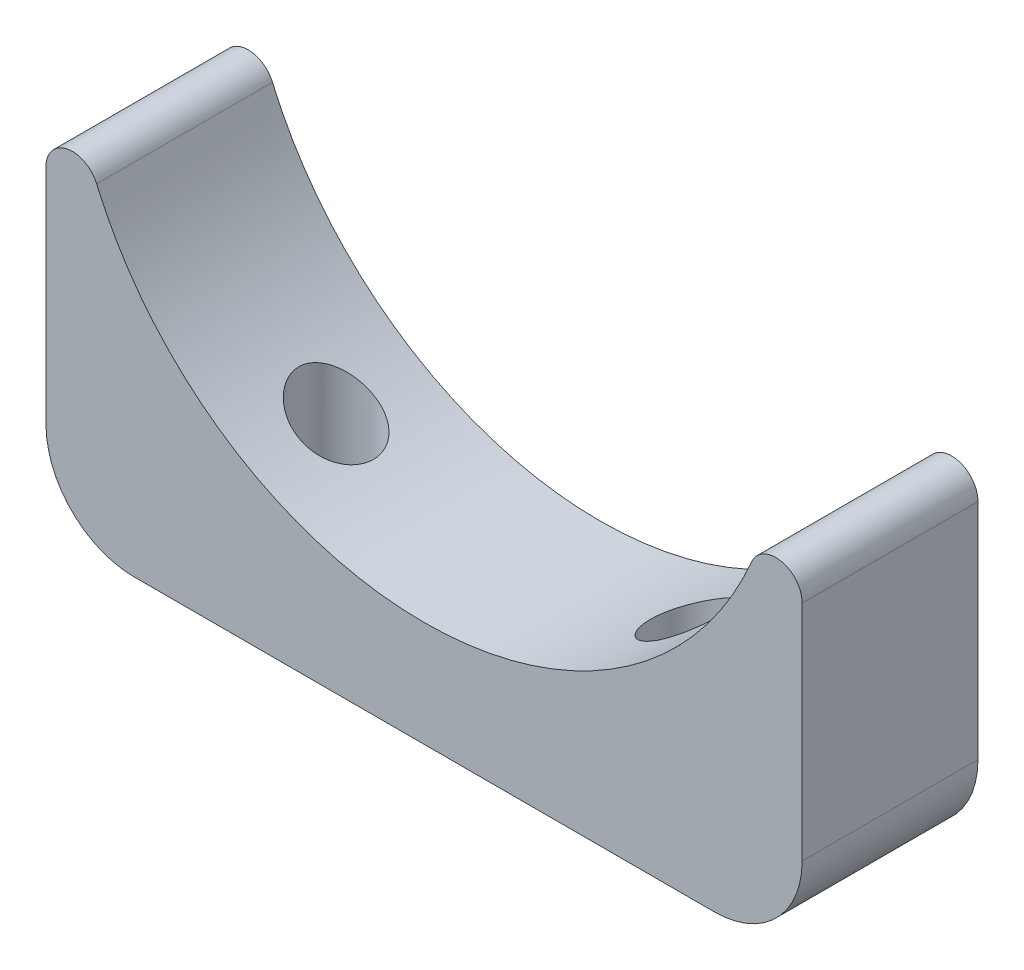
from build123d import *

# Parameters (mm, degrees)
BASE_EXTRUDE_DEPTH = 10
HOLE1_D            = 8.5
HOLE1_DEPTH        = 30
HOLE1_TIP          = 2.553657631


with BuildPart() as part:
    # Sketch1 → Base-Extrude (new body, symmetric)
    with BuildSketch(Plane.XY):
        with BuildLine():
            Line((43, -17.095320997), (43, -42.5))
            ThreePointArc((43, -42.5), (40.071067812, -49.571067812), (33, -52.5))
            Line((33, -52.5), (-33, -52.5))
            ThreePointArc((-33, -52.5), (-40.071067812, -49.571067812), (-43, -42.5))
            Line((-43, -42.5), (-43, -17.095320997))
            ThreePointArc((-43, -17.095320997), (-40.601721668, -14.156285265), (-37.24137931, -15.916333342))
            ThreePointArc((-37.24137931, -15.916333342), (0, -40.5), (37.24137931, -15.916333342))
            ThreePointArc((37.24137931, -15.916333342), (40.601721668, -14.156285265), (43, -17.095320997))
        make_face()
    extrude(amount=BASE_EXTRUDE_DEPTH, both=True)

    # Hole1
    with Locations(Plane.XZ.offset(52.5)):
        with Locations((-20, 0), (20, 0)):
            Hole(HOLE1_D / 2, depth=HOLE1_DEPTH)
            with Locations((0, 0, -(HOLE1_DEPTH + HOLE1_TIP / 2))):  # 118° drill point
                Cone(0, HOLE1_D / 2, HOLE1_TIP, mode=Mode.SUBTRACT)


solid = part.part
